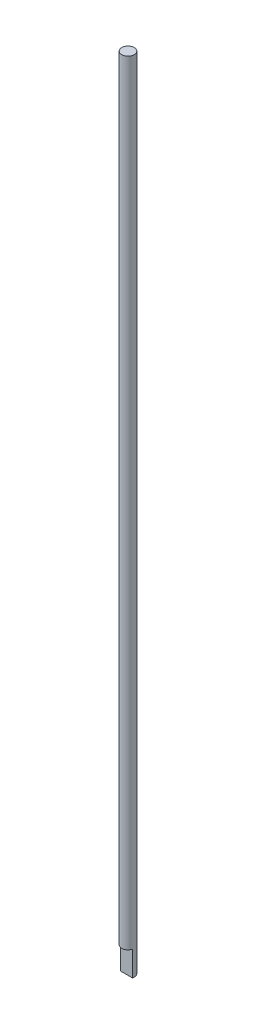
from build123d import *

# Parameters (mm, degrees)
SKETCH1_R           = 3.175
BOSS_EXTRUDE1_DEPTH = 406.4
SKETCH2_W           = 7.590384308
SKETCH2_H           = 2.596001261
CUT_EXTRUDE1_DEPTH  = 12.7


with BuildPart() as part:
    # Sketch1 → Boss-Extrude1 (new body)
    with BuildSketch(Plane(origin=(0, 0, 0), x_dir=(1, 0, 0), z_dir=(0, 1, 0))):
        Circle(SKETCH1_R)
    extrude(amount=BOSS_EXTRUDE1_DEPTH)

    # Sketch2 → Cut-Extrude1 (cut)
    with BuildSketch(Plane.XZ):
        with Locations((0.013474055, 2.075004468)):
            Rectangle(SKETCH2_W, SKETCH2_H)
    extrude(amount=-CUT_EXTRUDE1_DEPTH, mode=Mode.SUBTRACT)


solid = part.part
